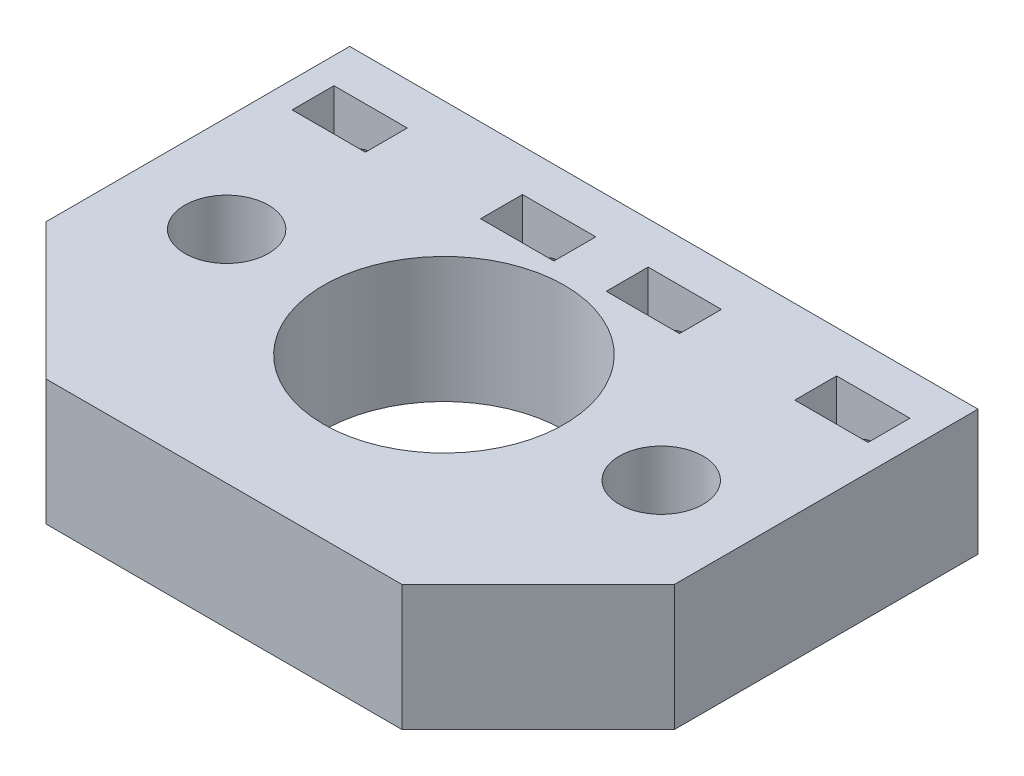
from build123d import *

# Parameters (mm, degrees)
SKETCH1_W                      = 60
SKETCH1_H                      = 42
BOSS_EXTRUDE1_DEPTH            = 12
CUT_EXTRUDE2_REACH             = 14
SKETCH3_R                      = 11.5
SKETCH3_R_2                    = 4
CUT_EXTRUDE2_DIRECTION_2_DEPTH = 1
CHAMFER1_SIZE                  = 13
CUT_EXTRUDE4_REACH             = 14
SKETCH5_W                      = 7
SKETCH5_H                      = 4
CUT_EXTRUDE4_DIRECTION_2_DEPTH = 1
SKETCH4_R                      = 2.25
CUT_EXTRUDE3_DEPTH             = 7.5


with BuildPart() as part:
    # Sketch1 → Boss-Extrude1 (new body)
    with BuildSketch(Plane(origin=(0, 0, 0), x_dir=(1, 0, 0), z_dir=(0, 1, 0))):
        Rectangle(SKETCH1_W, SKETCH1_H)
    extrude(amount=BOSS_EXTRUDE1_DEPTH)

    # Sketch3 → Cut-Extrude2 (cut, up to next)
    with BuildSketch(Plane(origin=(0, 12, 0), x_dir=(1, 0, 0), z_dir=(0, 1, 0)), mode=Mode.PRIVATE) as cut_extrude2_sk1:
        Circle(SKETCH3_R)
    cut_extrude2_tool1 = extrude(cut_extrude2_sk1.sketch, amount=-CUT_EXTRUDE2_REACH, mode=Mode.PRIVATE) & part.part
    add(cut_extrude2_tool1.solids().sort_by_distance((0, 12, 0))[0], mode=Mode.SUBTRACT)
    # Sketch3 → Cut-Extrude2 (cut, up to next)
    with BuildSketch(Plane(origin=(0, 12, 0), x_dir=(1, 0, 0), z_dir=(0, 1, 0)), mode=Mode.PRIVATE) as cut_extrude2_sk2:
        with Locations((20.75, 0)):
            Circle(SKETCH3_R_2)
    cut_extrude2_tool2 = extrude(cut_extrude2_sk2.sketch, amount=-CUT_EXTRUDE2_REACH, mode=Mode.PRIVATE) & part.part
    add(cut_extrude2_tool2.solids().sort_by_distance((20.75, 12, 0))[0], mode=Mode.SUBTRACT)
    # Sketch3 → Cut-Extrude2 (cut, up to next)
    with BuildSketch(Plane(origin=(0, 12, 0), x_dir=(1, 0, 0), z_dir=(0, 1, 0)), mode=Mode.PRIVATE) as cut_extrude2_sk3:
        with Locations((-20.75, 0)):
            Circle(SKETCH3_R_2)
    cut_extrude2_tool3 = extrude(cut_extrude2_sk3.sketch, amount=-CUT_EXTRUDE2_REACH, mode=Mode.PRIVATE) & part.part
    add(cut_extrude2_tool3.solids().sort_by_distance((-20.75, 12, 0))[0], mode=Mode.SUBTRACT)

    # Sketch3 → Cut-Extrude2 direction 2 (cut)
    with BuildSketch(Plane(origin=(0, 12, 0), x_dir=(1, 0, 0), z_dir=(0, 1, 0))):
        Circle(SKETCH3_R)
        with Locations((20.75, 0)):
            Circle(SKETCH3_R_2)
        with Locations((-20.75, 0)):
            Circle(SKETCH3_R_2)
    extrude(amount=CUT_EXTRUDE2_DIRECTION_2_DEPTH, mode=Mode.SUBTRACT)

    # Chamfer1
    chamfer1_edges = [part.edges().sort_by_distance(p)[0] for p in [
        (30, 6, 21),
        (-30, 6, 21),
    ]]
    chamfer(chamfer1_edges, length=CHAMFER1_SIZE)

    # Sketch5 → Cut-Extrude4 (cut, up to next)
    with BuildSketch(Plane(origin=(0, 12, 0), x_dir=(1, 0, 0), z_dir=(0, 1, 0)), mode=Mode.PRIVATE) as cut_extrude4_sk1:
        with Locations((24, 15)):
            Rectangle(SKETCH5_W, SKETCH5_H)
    cut_extrude4_tool1 = extrude(cut_extrude4_sk1.sketch, amount=-CUT_EXTRUDE4_REACH, mode=Mode.PRIVATE) & part.part
    add(cut_extrude4_tool1.solids().sort_by_distance((24, 12, -15))[0], mode=Mode.SUBTRACT)
    # Sketch5 → Cut-Extrude4 (cut, up to next)
    with BuildSketch(Plane(origin=(0, 12, 0), x_dir=(1, 0, 0), z_dir=(0, 1, 0)), mode=Mode.PRIVATE) as cut_extrude4_sk2:
        with Locations((6, 15)):
            Rectangle(SKETCH5_W, SKETCH5_H)
    cut_extrude4_tool2 = extrude(cut_extrude4_sk2.sketch, amount=-CUT_EXTRUDE4_REACH, mode=Mode.PRIVATE) & part.part
    add(cut_extrude4_tool2.solids().sort_by_distance((6, 12, -15))[0], mode=Mode.SUBTRACT)
    # Sketch5 → Cut-Extrude4 (cut, up to next)
    with BuildSketch(Plane(origin=(0, 12, 0), x_dir=(1, 0, 0), z_dir=(0, 1, 0)), mode=Mode.PRIVATE) as cut_extrude4_sk3:
        with Locations((-6, 15)):
            Rectangle(SKETCH5_W, SKETCH5_H)
    cut_extrude4_tool3 = extrude(cut_extrude4_sk3.sketch, amount=-CUT_EXTRUDE4_REACH, mode=Mode.PRIVATE) & part.part
    add(cut_extrude4_tool3.solids().sort_by_distance((-6, 12, -15))[0], mode=Mode.SUBTRACT)
    # Sketch5 → Cut-Extrude4 (cut, up to next)
    with BuildSketch(Plane(origin=(0, 12, 0), x_dir=(1, 0, 0), z_dir=(0, 1, 0)), mode=Mode.PRIVATE) as cut_extrude4_sk4:
        with Locations((-24, 15)):
            Rectangle(SKETCH5_W, SKETCH5_H)
    cut_extrude4_tool4 = extrude(cut_extrude4_sk4.sketch, amount=-CUT_EXTRUDE4_REACH, mode=Mode.PRIVATE) & part.part
    add(cut_extrude4_tool4.solids().sort_by_distance((-24, 12, -15))[0], mode=Mode.SUBTRACT)

    # Sketch5 → Cut-Extrude4 direction 2 (cut)
    with BuildSketch(Plane(origin=(0, 12, 0), x_dir=(1, 0, 0), z_dir=(0, 1, 0))):
        with Locations((24, 15)):
            Rectangle(SKETCH5_W, SKETCH5_H)
        with Locations((6, 15)):
            Rectangle(SKETCH5_W, SKETCH5_H)
        with Locations((-6, 15)):
            Rectangle(SKETCH5_W, SKETCH5_H)
        with Locations((-24, 15)):
            Rectangle(SKETCH5_W, SKETCH5_H)
    extrude(amount=CUT_EXTRUDE4_DIRECTION_2_DEPTH, mode=Mode.SUBTRACT)

    # Sketch4 → Cut-Extrude3 (cut)
    with BuildSketch(Plane(origin=(0, 0, -21), x_dir=(-1, 0, 0), z_dir=(0, 0, -1))):
        with Locations((-24, 6)):
            Circle(SKETCH4_R)
        with Locations((-6, 6)):
            Circle(SKETCH4_R)
        with Locations((6, 6)):
            Circle(SKETCH4_R)
        with Locations((24, 6)):
            Circle(SKETCH4_R)
    extrude(amount=-CUT_EXTRUDE3_DEPTH, mode=Mode.SUBTRACT)


solid = part.part
